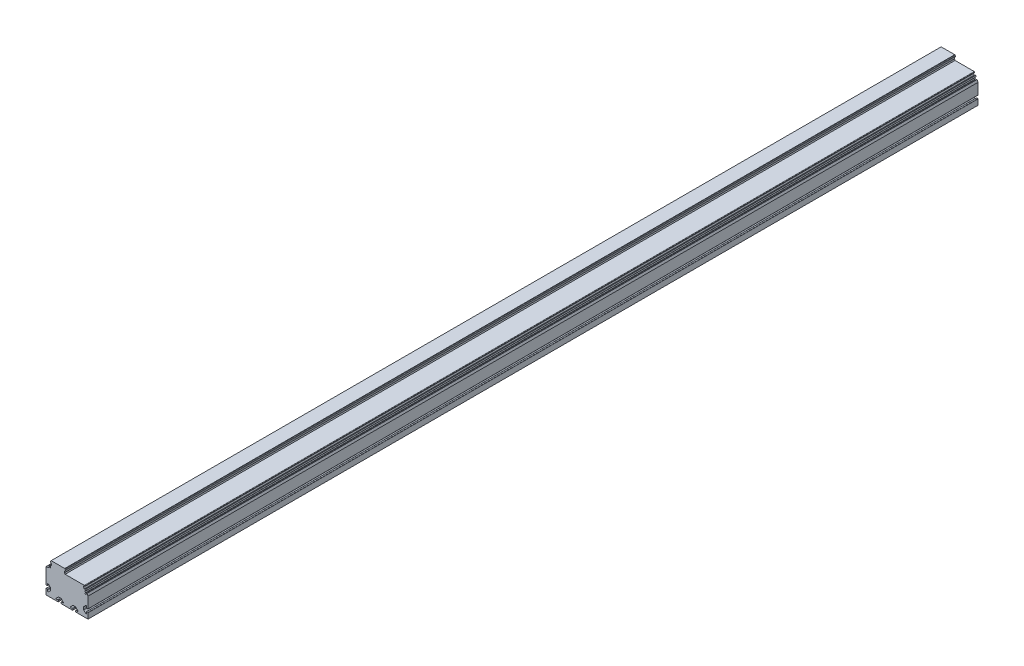
from build123d import *

# Parameters (mm, degrees)
BOSS_EXTRUDE1_DEPTH = 2456
SKETCH2_W           = 125
SKETCH2_H           = 100
CUT_EXTRUDE1_DEPTH  = 2456
BOSS_EXTRUDE2_DEPTH = 2456
CUT_EXTRUDE2_DEPTH  = 2


with BuildPart() as part:
    # Sketch1 → Boss-Extrude1 (new body)
    with BuildSketch(Plane.XY):
        Polygon((0, 0), (116, 0), (116, 55), (106.347431476, 75.7), (54, 75.7), (54, 89), (12, 89), (12, 75.9), (9.962990915, 75.9), (8, 72.5), (8, 68.3), (0, 68.3), align=None)
    extrude(amount=-BOSS_EXTRUDE1_DEPTH)

    # Sketch2 → Cut-Extrude1 (cut)
    with BuildSketch(Plane.XY):
        with Locations((57.5, 45)):
            Rectangle(SKETCH2_W, SKETCH2_H)
        with BuildLine():
            Line((0, 0), (33.3, 0))
            ThreePointArc((33.3, 0), (33.794974747, 0.205025253), (34, 0.7))
            Line((34, 0.7), (34, 3.8))
            ThreePointArc((34, 3.8), (33.794974747, 4.294974747), (33.3, 4.5))
            Line((33.3, 4.5), (31.306438242, 4.5))
            ThreePointArc((31.306438242, 4.5), (28.71887066, 3.886043748), (28.512563133, 6.537436867))
            Line((28.512563133, 6.537436867), (33.546446609, 11.571320344))
            ThreePointArc((33.546446609, 11.571320344), (34.519716656, 12.221638598), (35.667766953, 12.45))
            Line((35.667766953, 12.45), (40.332233047, 12.45))
            ThreePointArc((40.332233047, 12.45), (41.480283344, 12.221638598), (42.453553391, 11.571320344))
            Line((42.453553391, 11.571320344), (47.487436867, 6.537436867))
            ThreePointArc((47.487436867, 6.537436867), (47.28112934, 3.886043748), (44.693561758, 4.5))
            Line((44.693561758, 4.5), (42.7, 4.5))
            ThreePointArc((42.7, 4.5), (42.205025253, 4.294974747), (42, 3.8))
            Line((42, 3.8), (42, 0.7))
            ThreePointArc((42, 0.7), (42.205025253, 0.205025253), (42.7, 0))
            Line((42.7, 0), (73.3, 0))
            ThreePointArc((73.3, 0), (73.794974747, 0.205025253), (74, 0.7))
            Line((74, 0.7), (74, 3.8))
            ThreePointArc((74, 3.8), (73.794974747, 4.294974747), (73.3, 4.5))
            Line((73.3, 4.5), (71.306438242, 4.5))
            ThreePointArc((71.306438242, 4.5), (68.71887066, 3.886043748), (68.512563133, 6.537436867))
            Line((68.512563133, 6.537436867), (73.546446609, 11.571320344))
            ThreePointArc((73.546446609, 11.571320344), (74.519716656, 12.221638598), (75.667766953, 12.45))
            Line((75.667766953, 12.45), (80.332233047, 12.45))
            ThreePointArc((80.332233047, 12.45), (81.480283344, 12.221638598), (82.453553391, 11.571320344))
            Line((82.453553391, 11.571320344), (87.487436867, 6.537436867))
            ThreePointArc((87.487436867, 6.537436867), (87.28112934, 3.886043748), (84.693561758, 4.5))
            Line((84.693561758, 4.5), (82.7, 4.5))
            ThreePointArc((82.7, 4.5), (82.205025253, 4.294974747), (82, 3.8))
            Line((82, 3.8), (82, 0.7))
            ThreePointArc((82, 0.7), (82.205025253, 0.205025253), (82.7, 0))
            Line((82.7, 0), (116, 0))
            Line((116, 0), (116, 15.3))
            ThreePointArc((116, 15.3), (115.794974747, 15.794974747), (115.3, 16))
            Line((115.3, 16), (112.2, 16))
            ThreePointArc((112.2, 16), (111.705025253, 15.794974747), (111.5, 15.3))
            Line((111.5, 15.3), (111.5, 13.306438242))
            ThreePointArc((111.5, 13.306438242), (112.113956252, 10.71887066), (109.462563133, 10.512563133))
            Line((109.462563133, 10.512563133), (104.428679656, 15.546446609))
            ThreePointArc((104.428679656, 15.546446609), (103.778361402, 16.519716656), (103.55, 17.667766953))
            Line((103.55, 17.667766953), (103.55, 22.332233047))
            ThreePointArc((103.55, 22.332233047), (103.778361402, 23.480283344), (104.428679656, 24.453553391))
            Line((104.428679656, 24.453553391), (109.462563133, 29.487436867))
            ThreePointArc((109.462563133, 29.487436867), (112.113956252, 29.28112934), (111.5, 26.693561758))
            Line((111.5, 26.693561758), (111.5, 24.7))
            ThreePointArc((111.5, 24.7), (111.705025253, 24.205025253), (112.2, 24))
            Line((112.2, 24), (115.3, 24))
            ThreePointArc((115.3, 24), (115.794974747, 24.205025253), (116, 24.7))
            Line((116, 24.7), (116, 55))
            Line((116, 55), (113.46429043, 60.437846722))
            ThreePointArc((113.46429043, 60.437846722), (113.238575372, 60.644676466), (112.93272001, 60.631322532))
            Line((112.93272001, 60.631322532), (112.298304559, 60.335489749))
            ThreePointArc((112.298304559, 60.335489749), (112.194889687, 60.22263222), (112.201566654, 60.069704539))
            Line((112.201566654, 60.069704539), (112.604695845, 59.2051912))
            ThreePointArc((112.604695845, 59.2051912), (112.643945828, 58.90705798), (112.505095342, 58.640328679))
            Line((112.505095342, 58.640328679), (110.053506813, 56.18874015))
            ThreePointArc((110.053506813, 56.18874015), (107.93218647, 56.18874015), (107.93218647, 58.310060494))
            Line((107.93218647, 58.310060494), (108.871693413, 59.249567438))
            ThreePointArc((108.871693413, 59.249567438), (108.941118656, 59.382932088), (108.921493665, 59.531998698))
            Line((108.921493665, 59.531998698), (106.913588557, 63.837965099))
            ThreePointArc((106.913588557, 63.837965099), (106.900234623, 64.143820461), (107.107064367, 64.369535518))
            Line((107.107064367, 64.369535518), (109.463464613, 65.468342999))
            ThreePointArc((109.463464613, 65.468342999), (109.616392294, 65.475019965), (109.729249823, 65.371605094))
            Line((109.729249823, 65.371605094), (109.834904388, 65.145028147))
            ThreePointArc((109.834904388, 65.145028147), (109.947761917, 65.041613275), (110.100689598, 65.048290242))
            Line((110.100689598, 65.048290242), (110.735105049, 65.344123025))
            ThreePointArc((110.735105049, 65.344123025), (110.941934793, 65.569838082), (110.928580859, 65.875693444))
            Line((110.928580859, 65.875693444), (109.660726074, 68.594616806))
            ThreePointArc((109.660726074, 68.594616806), (109.435011016, 68.801446549), (109.129155654, 68.788092616))
            Line((109.129155654, 68.788092616), (108.494740203, 68.492259832))
            ThreePointArc((108.494740203, 68.492259832), (108.391325332, 68.379402304), (108.398002298, 68.226474623))
            Line((108.398002298, 68.226474623), (108.503656864, 67.999897676))
            ThreePointArc((108.503656864, 67.999897676), (108.510333831, 67.846969995), (108.406918959, 67.734112466))
            Line((108.406918959, 67.734112466), (106.050518712, 66.635304986))
            ThreePointArc((106.050518712, 66.635304986), (105.74466335, 66.621951052), (105.518948293, 66.828780796))
            Line((105.518948293, 66.828780796), (103.110024201, 71.994735182))
            ThreePointArc((103.110024201, 71.994735182), (103.096670268, 72.300590544), (103.303500011, 72.526305601))
            Line((103.303500011, 72.526305601), (105.659900257, 73.625113082))
            ThreePointArc((105.659900257, 73.625113082), (105.812827938, 73.631790049), (105.925685467, 73.528375177))
            Line((105.925685467, 73.528375177), (106.031340033, 73.30179823))
            ThreePointArc((106.031340033, 73.30179823), (106.144197561, 73.198383358), (106.297125242, 73.205060325))
            Line((106.297125242, 73.205060325), (106.931540693, 73.500893108))
            ThreePointArc((106.931540693, 73.500893108), (107.138370437, 73.726608166), (107.125016503, 74.032463528))
            Line((107.125016503, 74.032463528), (106.616669002, 75.122618262))
            ThreePointArc((106.616669002, 75.122618262), (106.247660824, 75.543391446), (105.710361215, 75.7))
            Line((105.710361215, 75.7), (52.770243927, 75.7))
            Line((52.770243927, 75.7), (51.1, 78.592947342))
            Line((51.1, 78.592947342), (51.1, 81.84))
            Line((51.1, 81.84), (52.670892773, 83.410892773))
            ThreePointArc((52.670892773, 83.410892773), (53.063837303, 84.151162697), (53.804107227, 84.544107227))
            Line((53.804107227, 84.544107227), (54, 84.74))
            Line((54, 84.74), (54, 86.75))
            Line((54, 86.75), (53.804107227, 86.945892773))
            ThreePointArc((53.804107227, 86.945892773), (53.063837303, 87.338837303), (52.670892773, 88.079107227))
            Line((52.670892773, 88.079107227), (51.75, 89))
            Line((51.75, 89), (14.25, 89))
            Line((14.25, 89), (13.329107227, 88.079107227))
            ThreePointArc((13.329107227, 88.079107227), (12.936162697, 87.338837303), (12.195892773, 86.945892773))
            Line((12.195892773, 86.945892773), (12, 86.75))
            Line((12, 86.75), (12, 84.74))
            Line((12, 84.74), (12.195892773, 84.544107227))
            ThreePointArc((12.195892773, 84.544107227), (12.936162697, 84.151162697), (13.329107227, 83.410892773))
            Line((13.329107227, 83.410892773), (14.9, 81.84))
            Line((14.9, 81.84), (14.9, 78.592947342))
            Line((14.9, 78.592947342), (12, 73.57))
            Line((12, 73.57), (12, 72.5))
            Line((12, 72.5), (13.45, 72.5))
            Line((13.45, 72.5), (13.45, 72.4))
            Line((13.45, 72.4), (13.25, 72.4))
            ThreePointArc((13.25, 72.4), (12.896446609, 72.253553391), (12.75, 71.9))
            Line((12.75, 71.9), (12.75, 70.9))
            ThreePointArc((12.75, 70.9), (12.603553391, 70.546446609), (12.25, 70.4))
            Line((12.25, 70.4), (12.05, 70.4))
            ThreePointArc((12.05, 70.4), (11.696446609, 70.546446609), (11.55, 70.9))
            Line((11.55, 70.9), (11.55, 71.443868259))
            ThreePointArc((11.55, 71.443868259), (11.494843796, 71.672153161), (11.341544012, 71.85007275))
            ThreePointArc((11.341544012, 71.85007275), (11.096264294, 72.134744107), (11.008014343, 72.5))
            Line((11.008014343, 72.5), (11.545442326, 75.547905547))
            ThreePointArc((11.545442326, 75.547905547), (11.479813333, 75.792836283), (11.25, 75.9))
            Line((11.25, 75.9), (10.25166605, 75.9))
            ThreePointArc((10.25166605, 75.9), (10.00166605, 75.833012702), (9.818653348, 75.65))
            Line((9.818653348, 75.65), (8.133974596, 72.732050808))
            ThreePointArc((8.133974596, 72.732050808), (8.034074174, 72.490869853), (8, 72.232050808))
            Line((8, 72.232050808), (8, 68.3))
            Line((8, 68.3), (1.2, 68.3))
            ThreePointArc((1.2, 68.3), (0.351471863, 67.948528137), (0, 67.1))
            Line((0, 67.1), (0, 24.7))
            ThreePointArc((0, 24.7), (0.205025253, 24.205025253), (0.7, 24))
            Line((0.7, 24), (3.8, 24))
            ThreePointArc((3.8, 24), (4.294974747, 24.205025253), (4.5, 24.7))
            Line((4.5, 24.7), (4.5, 26.693561758))
            ThreePointArc((4.5, 26.693561758), (3.886043748, 29.28112934), (6.537436867, 29.487436867))
            Line((6.537436867, 29.487436867), (11.571320344, 24.453553391))
            ThreePointArc((11.571320344, 24.453553391), (12.221638598, 23.480283344), (12.45, 22.332233047))
            Line((12.45, 22.332233047), (12.45, 17.667766953))
            ThreePointArc((12.45, 17.667766953), (12.221638598, 16.519716656), (11.571320344, 15.546446609))
            Line((11.571320344, 15.546446609), (6.537436867, 10.512563133))
            ThreePointArc((6.537436867, 10.512563133), (3.886043748, 10.71887066), (4.5, 13.306438242))
            Line((4.5, 13.306438242), (4.5, 15.3))
            ThreePointArc((4.5, 15.3), (4.294974747, 15.794974747), (3.8, 16))
            Line((3.8, 16), (0.7, 16))
            ThreePointArc((0.7, 16), (0.205025253, 15.794974747), (0, 15.3))
            Line((0, 15.3), (0, 0))
        make_face(mode=Mode.SUBTRACT)
    extrude(amount=-CUT_EXTRUDE1_DEPTH, mode=Mode.SUBTRACT)

    # Sketch3 → Boss-Extrude2 (add)
    with BuildSketch(Plane.XY):
        with BuildLine():
            Line((6, 67.3), (9, 67.3))
            Line((9, 67.3), (9, 70.3))
            Line((9, 70.3), (8, 70.3))
            ThreePointArc((8, 70.3), (7.414213562, 68.885786438), (6, 68.3))
            Line((6, 68.3), (6, 67.3))
        make_face()
    extrude(amount=-BOSS_EXTRUDE2_DEPTH)

    # Sketch4 → Cut-Extrude2 (cut)
    with BuildSketch(Plane.XY.offset(-2454)):
        with BuildLine():
            Line((64.324935076, 20.280574737), (85.288545319, 19.181918478))
            ThreePointArc((85.288545319, 19.181918478), (77.313632502, 67.565601322), (64.324935076, 20.280574737))
        make_face()
    extrude(amount=-CUT_EXTRUDE2_DEPTH, mode=Mode.SUBTRACT)


solid = part.part
